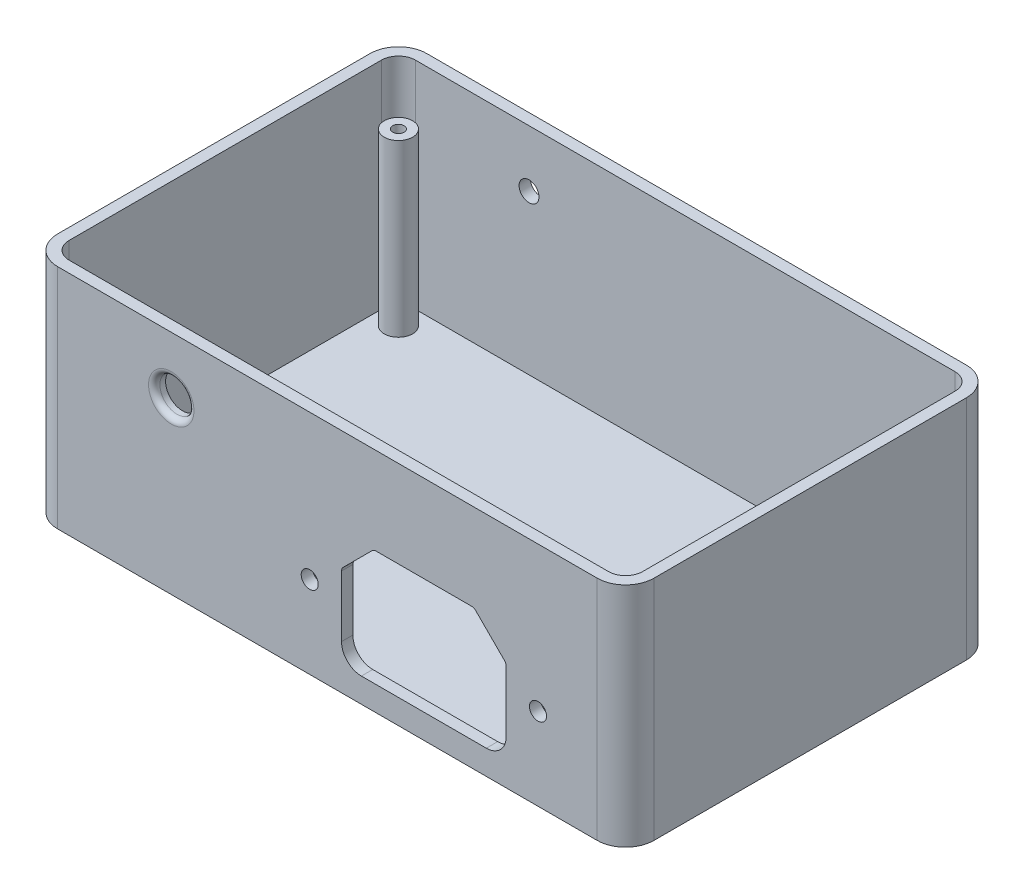
from build123d import *

# Parameters (mm, degrees)
SKETCH1_W                 = 105
SKETCH1_H                 = 65
BOSS_EXTRUDE1_DEPTH       = 40
FILLET1_R                 = 5
CUT_EXTRUDE1_DEPTH        = 38
SKETCH4_R                 = 2.5
SKETCH4_R_2               = 1
BOSS_EXTRUDE2_DEPTH       = 30
MIRROR2_COPY_1_SKETCH_R   = 2.5
MIRROR2_COPY_1_SKETCH_R_2 = 1
MIRROR2_COPY_1_DEPTH      = 30
CUT_EXTRUDE2_REACH        = 67
SKETCH7_R                 = 1.5
CUT_EXTRUDE3_REACH        = 4
SKETCH9_R                 = 2
CUT_EXTRUDE4_REACH        = 67
SKETCH12_R                = 3
FILLET2_R                 = 1
CUT_EXTRUDE5_REACH        = 67
SKETCH13_R                = 1.75


with BuildPart() as part:
    # Sketch1 → Boss-Extrude1 (new body)
    with BuildSketch(Plane(origin=(0, 0, 0), x_dir=(1, 0, 0), z_dir=(0, 1, 0))):
        with Locations((52.5, 32.5)):
            Rectangle(SKETCH1_W, SKETCH1_H)
    extrude(amount=BOSS_EXTRUDE1_DEPTH)

    # Fillet1
    fillet1_edges = [part.edges().sort_by_distance(p)[0] for p in [
        (0, 20, 0),
        (0, 20, -65),
        (105, 20, -65),
        (105, 20, 0),
    ]]
    fillet(fillet1_edges, radius=FILLET1_R)

    # Sketch3 → Cut-Extrude1 (cut)
    with BuildSketch(Plane(origin=(0, 40, 0), x_dir=(1, 0, 0), z_dir=(0, 1, 0))):
        with BuildLine():
            Line((100, 63), (5, 63))
            ThreePointArc((5, 63), (2.878679656, 62.121320344), (2, 60))
            Line((2, 60), (2, 5))
            ThreePointArc((2, 5), (2.878679656, 2.878679656), (5, 2))
            Line((5, 2), (100, 2))
            ThreePointArc((100, 2), (102.121320344, 2.878679656), (103, 5))
            Line((103, 5), (103, 60))
            ThreePointArc((103, 60), (102.121320344, 62.121320344), (100, 63))
        make_face()
    extrude(amount=-CUT_EXTRUDE1_DEPTH, mode=Mode.SUBTRACT)

    # Sketch4 → Boss-Extrude2 (add)
    with BuildSketch(Plane(origin=(0, 2, 0), x_dir=(1, 0, 0), z_dir=(0, 1, 0))):
        with Locations((99, 6)):
            Circle(SKETCH4_R)
        with Locations((99, 6)):
            Circle(SKETCH4_R_2, mode=Mode.SUBTRACT)
    boss_extrude2 = extrude(amount=BOSS_EXTRUDE2_DEPTH)

    # Mirror1: Boss-Extrude2 across plane
    add(boss_extrude2.mirror(Plane(origin=(0, 0, -32.5), x_dir=(1, 0, 0), z_dir=(0, 0, -1))))

    # Mirror2: Boss-Extrude2 across plane
    add(boss_extrude2.mirror(Plane.ZY.offset(-52.5)))

    # Mirror2 copy 1 sketch → Mirror2 copy 1 (add)
    with BuildSketch(Plane(origin=(105, 2, -65), x_dir=(-1, 0, 0), z_dir=(0, 1, 0))):
        with Locations((99, 6)):
            Circle(MIRROR2_COPY_1_SKETCH_R)
        with Locations((99, 6)):
            Circle(MIRROR2_COPY_1_SKETCH_R_2, mode=Mode.SUBTRACT)
    extrude(amount=MIRROR2_COPY_1_DEPTH)

    # Sketch7 → Cut-Extrude2 (cut, up to next)
    with BuildSketch(Plane.XY, mode=Mode.PRIVATE) as cut_extrude2_sk1:
        with Locations((89.576612985, 14.483747467)):
            Circle(SKETCH7_R)
    cut_extrude2_tool1 = extrude(cut_extrude2_sk1.sketch, amount=-CUT_EXTRUDE2_REACH, mode=Mode.PRIVATE) & part.part
    add(cut_extrude2_tool1.solids().sort_by_distance((89.576613, 14.483747, 0))[0], mode=Mode.SUBTRACT)
    # Sketch7 → Cut-Extrude2 (cut, up to next)
    with BuildSketch(Plane.XY, mode=Mode.PRIVATE) as cut_extrude2_sk2:
        with Locations((49.376612985, 14.483747467)):
            Circle(SKETCH7_R)
    cut_extrude2_tool2 = extrude(cut_extrude2_sk2.sketch, amount=-CUT_EXTRUDE2_REACH, mode=Mode.PRIVATE) & part.part
    add(cut_extrude2_tool2.solids().sort_by_distance((49.376613, 14.483747, 0))[0], mode=Mode.SUBTRACT)
    # Sketch7 → Cut-Extrude2 (cut, up to next)
    with BuildSketch(Plane.XY, mode=Mode.PRIVATE) as cut_extrude2_sk3:
        with BuildLine():
            Line((83.683719766, 19.28006781), (78.597933329, 24.365854248))
            ThreePointArc((78.597933329, 24.365854248), (78.27350998, 24.582626999), (77.890826547, 24.658747467))
            Line((77.890826547, 24.658747467), (61.062399423, 24.658747467))
            ThreePointArc((61.062399423, 24.658747467), (60.67971599, 24.582626999), (60.355292641, 24.365854248))
            Line((60.355292641, 24.365854248), (55.269506204, 19.28006781))
            ThreePointArc((55.269506204, 19.28006781), (55.052733452, 18.955644461), (54.976612985, 18.572961029))
            Line((54.976612985, 18.572961029), (54.976612985, 7.808747467))
            ThreePointArc((54.976612985, 7.808747467), (56.001739251, 5.333873733), (58.476612985, 4.308747467))
            Line((58.476612985, 4.308747467), (80.476612985, 4.308747467))
            ThreePointArc((80.476612985, 4.308747467), (82.951486719, 5.333873733), (83.976612985, 7.808747467))
            Line((83.976612985, 7.808747467), (83.976612985, 18.572961029))
            ThreePointArc((83.976612985, 18.572961029), (83.900492517, 18.955644461), (83.683719766, 19.28006781))
        make_face()
    cut_extrude2_tool3 = extrude(cut_extrude2_sk3.sketch, amount=-CUT_EXTRUDE2_REACH, mode=Mode.PRIVATE) & part.part
    add(cut_extrude2_tool3.solids().sort_by_distance((69.476613, 14.089774, 0))[0], mode=Mode.SUBTRACT)

    # Sketch9 → Cut-Extrude3 (cut, up to next)
    with BuildSketch(Plane(origin=(0, 2, 0), x_dir=(1, 0, 0), z_dir=(0, 1, 0)), mode=Mode.PRIVATE) as cut_extrude3_sk1:
        with Locations((93, 32.5)):
            Circle(SKETCH9_R)
    cut_extrude3_tool1 = extrude(cut_extrude3_sk1.sketch, amount=-CUT_EXTRUDE3_REACH, mode=Mode.PRIVATE) & part.part
    add(cut_extrude3_tool1.solids().sort_by_distance((93, 2, -32.5))[0], mode=Mode.SUBTRACT)
    # Sketch9 → Cut-Extrude3 (cut, up to next)
    with BuildSketch(Plane(origin=(0, 2, 0), x_dir=(1, 0, 0), z_dir=(0, 1, 0)), mode=Mode.PRIVATE) as cut_extrude3_sk2:
        with Locations((12, 32.5)):
            Circle(SKETCH9_R)
    cut_extrude3_tool2 = extrude(cut_extrude3_sk2.sketch, amount=-CUT_EXTRUDE3_REACH, mode=Mode.PRIVATE) & part.part
    add(cut_extrude3_tool2.solids().sort_by_distance((12, 2, -32.5))[0], mode=Mode.SUBTRACT)

    # Sketch12 → Cut-Extrude4 (cut, up to next)
    with BuildSketch(Plane.XY, mode=Mode.PRIVATE) as cut_extrude4_sk1:
        with Locations((25, 30)):
            Circle(SKETCH12_R)
    cut_extrude4_tool1 = extrude(cut_extrude4_sk1.sketch, amount=-CUT_EXTRUDE4_REACH, mode=Mode.PRIVATE) & part.part
    add(cut_extrude4_tool1.solids().sort_by_distance((25, 30, 0))[0], mode=Mode.SUBTRACT)

    # Fillet2
    fillet2_edges = [part.edges().sort_by_distance(p)[0] for p in [
        (22, 30, 0),
    ]]
    fillet(fillet2_edges, radius=FILLET2_R)

    # Sketch13 → Cut-Extrude5 (cut, up to next)
    with BuildSketch(Plane(origin=(0, 0, -65), x_dir=(-1, 0, 0), z_dir=(0, 0, -1)), mode=Mode.PRIVATE) as cut_extrude5_sk1:
        with Locations((-25, 30)):
            Circle(SKETCH13_R)
    cut_extrude5_tool1 = extrude(cut_extrude5_sk1.sketch, amount=-CUT_EXTRUDE5_REACH, mode=Mode.PRIVATE) & part.part
    add(cut_extrude5_tool1.solids().sort_by_distance((25, 30, -65))[0], mode=Mode.SUBTRACT)


solid = part.part
